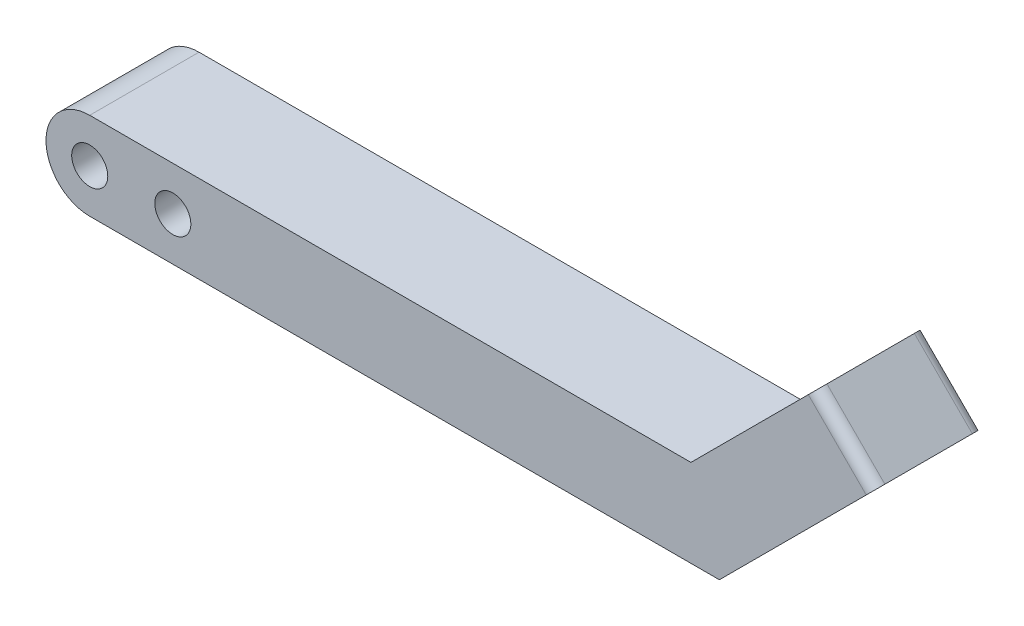
from build123d import *

# Parameters (mm, degrees)
SKETCH1_R           = 1.65
BOSS_EXTRUDE1_DEPTH = 10
SKETCH2_R           = 2
CUT_EXTRUDE1_DEPTH  = 18.495331881
FILLET1_R           = 1


with BuildPart() as part:
    # Sketch1 → Boss-Extrude1 (new body)
    with BuildSketch(Plane.XY):
        with BuildLine():
            Line((12.688854384, 4.179140788), (-42.311145616, 4.179140788))
            ThreePointArc((-42.311145616, 4.179140788), (-46.311145616, 0.179140788), (-42.311145616, -3.820859212))
            Line((-42.311145616, -3.820859212), (15.288854384, -3.820859212))
            Line((15.288854384, -3.820859212), (29.430990008, 10.321276412))
            Line((29.430990008, 10.321276412), (24.130990008, 15.621276412))
            Line((24.130990008, 15.621276412), (12.688854384, 4.179140788))
        make_face()
        with Locations((-34.711145616, 0.179140788)):
            Circle(SKETCH1_R, mode=Mode.SUBTRACT)
        with Locations((-42.311145616, 0.179140788)):
            Circle(SKETCH1_R, mode=Mode.SUBTRACT)
    extrude(amount=BOSS_EXTRUDE1_DEPTH)

    # Sketch2 → Cut-Extrude1 (cut, through all)
    with BuildSketch(Plane(origin=(4.254856798, -4.254856798, 0), x_dir=(0, 0, 1), z_dir=(-0.707106781, 0.707106781, 0))):
        with Locations((5, 20.018285462)):
            Circle(SKETCH2_R)
    extrude(amount=-CUT_EXTRUDE1_DEPTH, mode=Mode.SUBTRACT)

    # Fillet1
    fillet1_edges = [part.edges().sort_by_distance(p)[0] for p in [
        (26.780990008, 12.971276412, 0),
        (26.780990008, 12.971276412, 10),
    ]]
    fillet(fillet1_edges, radius=FILLET1_R)


solid = part.part
